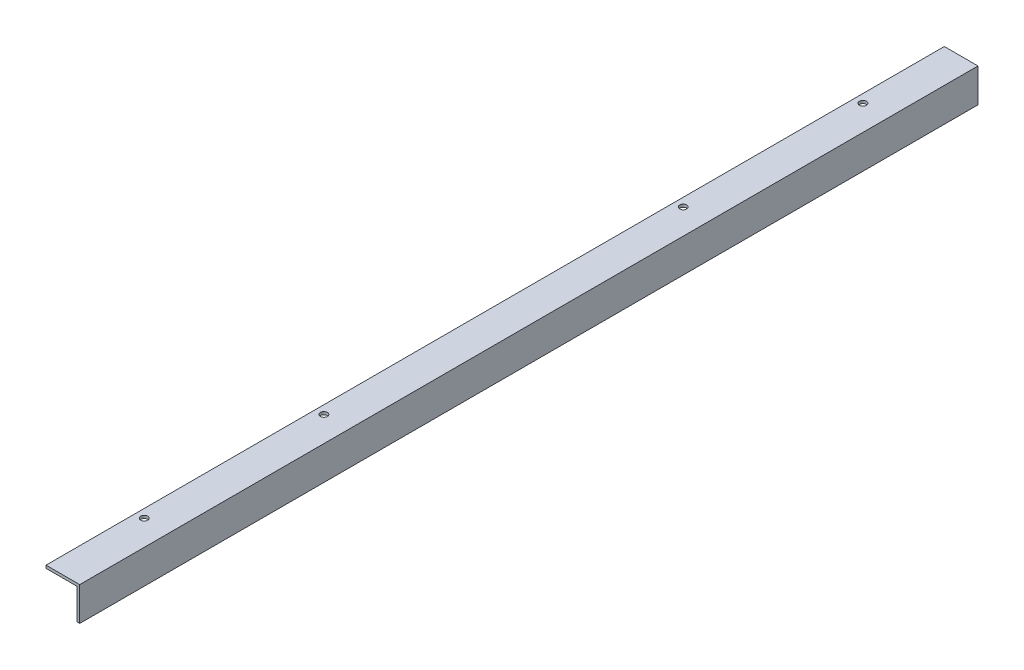
from build123d import *

# Parameters (mm, degrees)
BOSS_EXTRUDE1_DEPTH = 1016
SKETCH4_R           = 3.96875
CUT_EXTRUDE3_DEPTH  = 44.45
LPATTERN1_COUNT     = 5
LPATTERN1_PITCH     = 203.2


with BuildPart() as part:
    # Sketch1 → Boss-Extrude1 (new body)
    with BuildSketch(Plane.XY):
        Polygon((0, 0), (-38.1, 0), (-38.1, -3.175), (-3.175, -3.175), (-3.175, -38.1), (0, -38.1), align=None)
    extrude(amount=BOSS_EXTRUDE1_DEPTH)

    # Sketch4 → Cut-Extrude3 (cut)
    with BuildSketch(Plane(origin=(10.670100368, 3.175, 791.563272881), x_dir=(1, 0, 0), z_dir=(0, 1, 0))):
        with Locations((-39.245100368, 689.963272881)):
            Circle(SKETCH4_R)
    cut_extrude3 = extrude(amount=-CUT_EXTRUDE3_DEPTH, mode=Mode.SUBTRACT)

    # LPattern1: Cut-Extrude3 ×5, 1 skipped
    with Locations(*[(0, 0, i * LPATTERN1_PITCH) for i in range(1, LPATTERN1_COUNT) if i not in (2,)]):
        add(cut_extrude3, mode=Mode.SUBTRACT)


solid = part.part
